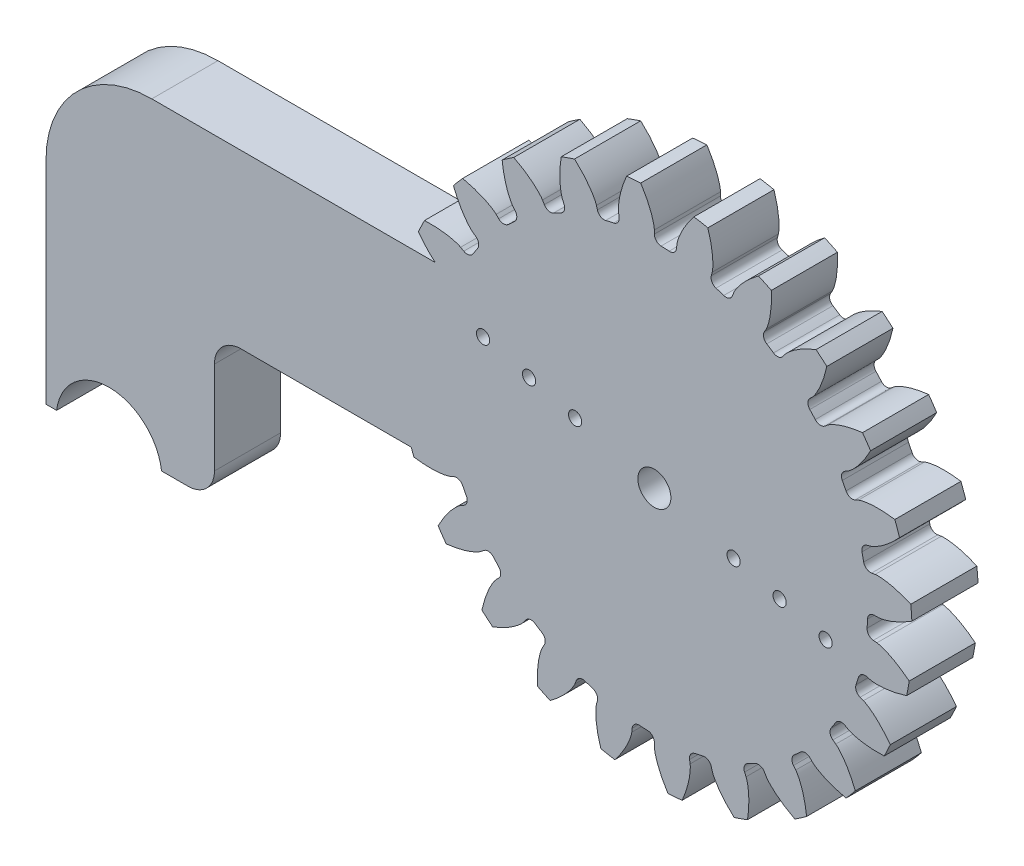
from build123d import *

# Parameters (mm, degrees)
SKETCH_1_R                       = 19.5
EXTRUDE_1_DEPTH                  = 2.5
CUT_EXTRUDE_1_DEPTH              = 3.5
FILLET_1_R                       = 0.525
PATTERN_CIRCULAR_1_COUNT         = 24
FILLET_1_OF_PATTERN_CIRCULAR_1_R = 0.525
SKETCH_7_R                       = 1.25
CUT_EXTRUDE_3_DEPTH              = 10
SKETCH_8_R                       = 0.5
CUT_EXTRUDE_4_DEPTH              = 10
EXTRUDE_2_DEPTH                  = 5
SKETCH_11_R                      = 0.5
CUT_EXTRUDE_5_DEPTH              = 5
FILLET_2_R                       = 2
FILLET_3_R                       = 2
FILLET_4_R                       = 8


with BuildPart() as part:
    # 草图1 → 凸台-拉伸1 (new body, symmetric)
    with BuildSketch(Plane.XY):
        Circle(SKETCH_1_R)
    extrude(amount=EXTRUDE_1_DEPTH, both=True)

    # 草图4 → 切除-拉伸1 (cut, symmetric)
    with BuildSketch(Plane.XY):
        with BuildLine():
            Line((16.914467174, 0), (16.125, 0))
            ThreePointArc((16.125, 0), (16.104406002, -0.814697695), (16.04267661, -1.627314412))
            Line((16.04267661, -1.627314412), (16.828113296, -1.706986431))
            add(Edge.make_bspline(
                [(16.828113296, -1.706986431), (16.840527681, -1.708511688), (16.875237155, -1.713601645), (16.940385284, -1.72642548), (17.04578575, -1.75185716), (17.178580785, -1.790840016), (17.348168256, -1.848696583), (17.54500963, -1.926359478), (17.757874619, -2.021535782), (17.985348853, -2.135522507), (18.208357518, -2.258343877), (18.426895804, -2.389194021), (18.640882701, -2.526970155), (18.895429995, -2.702464535), (19.193996006, -2.924767557), (19.532565422, -3.201386652), (19.903721108, -3.534555431), (20.267325509, -3.894072436), (20.612744384, -4.264002566), (20.9466773, -4.655469783), (21.259020212, -5.046739901), (21.567017581, -5.470150923), (21.843015964, -5.869742666), (22.133182877, -6.335114454), (22.361853272, -6.715951293), (22.58164624, -7.123307329), (22.686172139, -7.323587215), (22.738546637, -7.426768909)],
                knots=[0, 0, 0, 0, 0, 0.005376748, 0.015083688, 0.02853182, 0.046610139, 0.064854849, 0.092110525, 0.119476175, 0.146842495, 0.174208853, 0.201574955, 0.228941013, 0.256307345, 0.307035032, 0.361767351, 0.41649966, 0.471231936, 0.525964281, 0.580696615, 0.635428982, 0.690161387, 0.744893688, 0.799626083, 0.854358408, 0.909088956, 0.909088956, 0.909088956, 0.909088956, 0.909088956], degree=4))
            ThreePointArc((22.738546637, -7.426768909), (23.890118663, -1.208565197), (23.371958967, 5.094107734))
            add(Edge.make_bspline(
                [(16.914467174, 0), (16.926972094, 0.000264626), (16.962018003, 0.001825759), (17.02812763, 0.008009448), (17.13555642, 0.02267439), (17.271607462, 0.048056683), (17.446167779, 0.088503263), (17.649841661, 0.1459046), (17.87122477, 0.219112829), (18.109040851, 0.309561074), (18.343305751, 0.409249507), (18.573933354, 0.517376858), (18.800731774, 0.632854149), (19.07168996, 0.781763773), (19.391165969, 0.972800693), (19.755922635, 1.213839224), (20.158806113, 1.507850097), (20.556835908, 1.828836711), (20.937823927, 2.162018534), (21.309558148, 2.517786612), (21.659792724, 2.875537433), (22.008947584, 3.265703576), (22.323863042, 3.635401372), (22.659513149, 4.069113436), (22.925449576, 4.424928384), (23.185230209, 4.808023009), (23.309434429, 4.996731535), (23.371958967, 5.094107734)],
                knots=[0, 0, 0, 0, 0, 0.005376748, 0.015083688, 0.02853182, 0.046610139, 0.064854849, 0.092110525, 0.119476175, 0.146842495, 0.174208853, 0.201574955, 0.228941013, 0.256307345, 0.307035032, 0.361767351, 0.41649966, 0.471231936, 0.525964281, 0.580696615, 0.635428982, 0.690161387, 0.744893688, 0.799626083, 0.854358408, 0.909090916, 0.909090916, 0.909090916, 0.909090916, 0.909090916], degree=4))
        make_face()
    cut_extrude_1 = extrude(amount=CUT_EXTRUDE_1_DEPTH, both=True, mode=Mode.SUBTRACT)

    # 圆角1
    fillet_1_edges = [part.edges().sort_by_distance(p)[0] for p in [
        (16.04267661, -1.627314412, 0),
        (16.125, 0, 0),
    ]]
    fillet(fillet_1_edges, radius=FILLET_1_R)

    # 阵列(圆周)1: 切除-拉伸1 ×24 about axis
    pattern_circular_1_axis = Axis((0, 0, 2.5), (0, 0, -1))
    for i in range(1, PATTERN_CIRCULAR_1_COUNT):
        add(cut_extrude_1.rotate(pattern_circular_1_axis, i * 360 / PATTERN_CIRCULAR_1_COUNT), mode=Mode.SUBTRACT)

    # 圆角1 of 阵列(圆周)1
    fillet_1_of_pattern_circular_1_edges = [part.edges().sort_by_distance(p)[0] for p in [
        (15.074855698, -5.724015259, 0),
        (15.575553949, -4.173457102, 0),
        (13.079708283, -9.430633926, 0),
        (13.964659636, -8.0625, 0),
        (10.193200363, -12.494570475, 0),
        (11.402096847, -11.402096847, 0),
        (6.612042684, -14.707022695, 0),
        (8.0625, -13.964659636, 0),
        (2.580285223, -15.917215622, 0),
        (4.173457102, -15.575553949, 0),
        (-1.627314412, -16.04267661, 0),
        (0, -16.125, 0),
        (-5.724015259, -15.074855698, 0),
        (-4.173457102, -15.575553949, 0),
        (-9.430633926, -13.079708283, 0),
        (-8.0625, -13.964659636, 0),
        (-12.494570475, -10.193200363, 0),
        (-11.402096847, -11.402096847, 0),
        (-14.707022695, -6.612042684, 0),
        (-13.964659636, -8.0625, 0),
        (-15.917215622, -2.580285223, 0),
        (-15.575553949, -4.173457102, 0),
        (-16.04267661, 1.627314412, 0),
        (-16.125, 0, 0),
        (-15.074855698, 5.724015259, 0),
        (-15.575553949, 4.173457102, 0),
        (-13.079708283, 9.430633926, 0),
        (-13.964659636, 8.0625, 0),
        (-10.193200363, 12.494570475, 0),
        (-11.402096847, 11.402096847, 0),
        (-6.612042684, 14.707022695, 0),
        (-8.0625, 13.964659636, 0),
        (-2.580285223, 15.917215622, 0),
        (-4.173457102, 15.575553949, 0),
        (1.627314412, 16.04267661, 0),
        (0, 16.125, 0),
        (5.724015259, 15.074855698, 0),
        (4.173457102, 15.575553949, 0),
        (9.430633926, 13.079708283, 0),
        (8.0625, 13.964659636, 0),
        (12.494570475, 10.193200363, 0),
        (11.402096847, 11.402096847, 0),
        (14.707022695, 6.612042684, 0),
        (13.964659636, 8.0625, 0),
        (15.917215622, 2.580285223, 0),
        (15.575553949, 4.173457102, 0),
    ]]
    fillet(fillet_1_of_pattern_circular_1_edges, radius=FILLET_1_OF_PATTERN_CIRCULAR_1_R)

    # 草图7 → 切除-拉伸3 (cut)
    with BuildSketch(Plane.XY.offset(2.5)):
        Circle(SKETCH_7_R)
    extrude(amount=-CUT_EXTRUDE_3_DEPTH, mode=Mode.SUBTRACT)

    # 草图8 → 切除-拉伸4 (cut)
    with BuildSketch(Plane(origin=(0, 0, -2.5), x_dir=(-1, 0, 0), z_dir=(0, 0, -1))):
        with Locations((12.951541263, 3.437670564)):
            Circle(SKETCH_8_R)
        with Locations((9.472022715, 2.514117278)):
            Circle(SKETCH_8_R)
        with Locations((-9.472022715, -2.514117278)):
            Circle(SKETCH_8_R)
        with Locations((-12.951541263, -3.437670564)):
            Circle(SKETCH_8_R)
    extrude(amount=-CUT_EXTRUDE_4_DEPTH, mode=Mode.SUBTRACT)

    # 草图10 → 凸台-拉伸2 (add)
    with BuildSketch(Plane(origin=(0, 0, -2.5), x_dir=(-1, 0, 0), z_dir=(0, 0, -1))):
        with BuildLine():
            Line((14, 6.5), (14, -6.5))
            Line((14, -6.5), (33.262746067, -6.5))
            Line((33.262746067, -6.5), (33.262746067, -17.5))
            Line((33.262746067, -17.5), (37.262746067, -17.5))
            ThreePointArc((37.262746067, -17.5), (41.231373033, -14), (45.2, -17.5))
            Line((45.2, -17.5), (46, -17.5))
            Line((46, -17.5), (46, 6.5))
            Line((46, 6.5), (14, 6.5))
        make_face()
    extrude(amount=-EXTRUDE_2_DEPTH)

    # 草图11 → 切除-拉伸5 (cut)
    with BuildSketch(Plane(origin=(0, 0, -2.5), x_dir=(-1, 0, 0), z_dir=(0, 0, -1))):
        with Locations((5.992504167, 1.590563992)):
            Circle(SKETCH_11_R)
        with Locations((-5.992504167, -1.590563992)):
            Circle(SKETCH_11_R)
    extrude(amount=-CUT_EXTRUDE_5_DEPTH, mode=Mode.SUBTRACT)

    # 圆角2
    fillet_2_edges = [part.edges().sort_by_distance(p)[0] for p in [
        (-33.262746067, -6.5, 0),
    ]]
    fillet(fillet_2_edges, radius=FILLET_2_R)

    # 圆角3
    fillet_3_edges = [part.edges().sort_by_distance(p)[0] for p in [
        (-33.262746067, -17.5, 0),
    ]]
    fillet(fillet_3_edges, radius=FILLET_3_R)

    # 圆角4
    fillet_4_edges = [part.edges().sort_by_distance(p)[0] for p in [
        (-46, 6.5, 0),
    ]]
    fillet(fillet_4_edges, radius=FILLET_4_R)


solid = part.part
